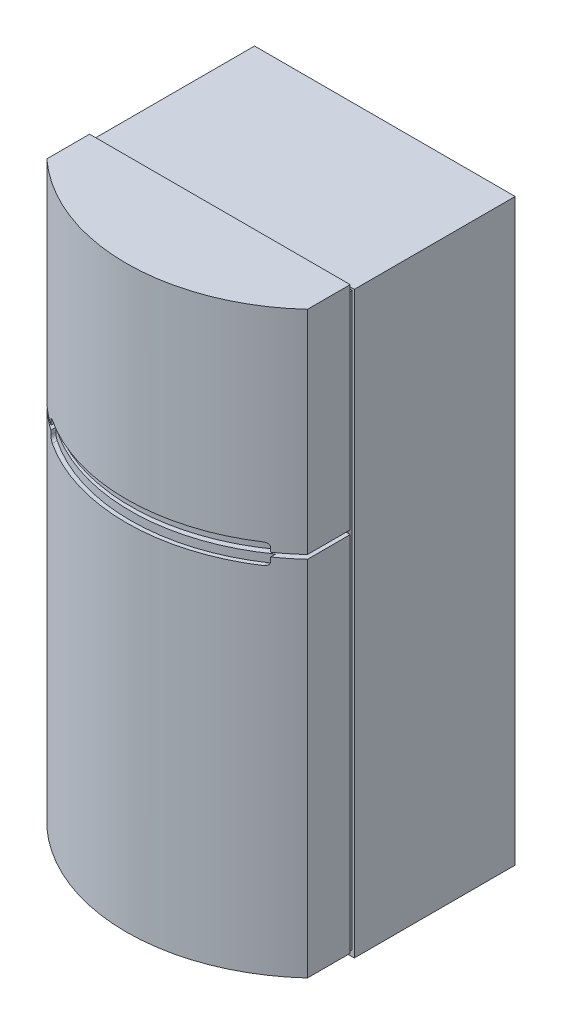
from build123d import *

# Parameters (mm, degrees)
SKETCH1_W               = 810
SKETCH1_H               = 500
BOSS_EXTRUDE1_DEPTH     = 1800
BOSS_EXTRUDE2_START     = 19.05
BOSS_EXTRUDE2_DEPTH     = 1800
SKETCH3_W               = 810
SKETCH3_H               = 12.7
CUT_EXTRUDE1_DEPTH      = 1712.976
CUT_EXTRUDE2_REACH      = 2031.39
CUT_EXTRUDE2_END_RADIUS = 585.872014924
SKETCH5_W               = 797.3
SKETCH5_H               = 1774.6
SKETCH5_W_2             = 771.9
SKETCH5_H_2             = 1749.2
EXTRUDE_THIN1_DEPTH     = 12.7
CUT_EXTRUDE3_DEPTH      = 1930.499391797


with BuildPart() as part:
    # Sketch1 → Boss-Extrude1 (new body)
    with BuildSketch(Plane(origin=(0, 0, 0), x_dir=(1, 0, 0), z_dir=(0, 1, 0))):
        Rectangle(SKETCH1_W, SKETCH1_H)
    extrude(amount=BOSS_EXTRUDE1_DEPTH)

    # Sketch6 → Cut-Extrude3 (cut, through all)
    with BuildSketch(Plane.XY.offset(250)):
        Polygon((-302.626047731, 0), (-268.027399007, 13.483618078), (268.027399007, 13.483618078), (302.626047731, 0), align=None)
    extrude(amount=-CUT_EXTRUDE3_DEPTH, mode=Mode.SUBTRACT)


with BuildPart() as body_2:
    # Sketch2 → Boss-Extrude2 (new body)
    with BuildSketch(Plane(origin=(0, 0, 0), x_dir=(1, 0, 0), z_dir=(0, 1, 0)).offset(BOSS_EXTRUDE2_START)):
        with BuildLine():
            Line((-405, -262.7), (405, -262.7))
            Line((405, -262.7), (405, -395.583268728))
            ThreePointArc((405, -395.583268728), (0, -553.402), (-405, -395.583268728))
            Line((-405, -395.583268728), (-405, -262.7))
        make_face()
    extrude(amount=BOSS_EXTRUDE2_DEPTH)

    # Sketch3 → Cut-Extrude1 (cut)
    with BuildSketch(Plane.XY.offset(553.402)):
        with Locations((0, 1152.493299562)):
            Rectangle(SKETCH3_W, SKETCH3_H)
    extrude(amount=-CUT_EXTRUDE1_DEPTH, mode=Mode.SUBTRACT)


with BuildPart() as cut_extrude1_piece_1:
    # of the separate pieces the step leaves, piece 1, a body of its own (cut_extrude1_pieces)
    add(body_2.part.solids().sort_by_distance((-405, 19.05, 395.583268728))[0])


with BuildPart() as cut_extrude1_piece_2:
    # of the separate pieces the step leaves, piece 2, a body of its own (cut_extrude1_pieces)
    add(body_2.part.solids().sort_by_distance((-405, 1158.843299562, 395.583268728))[0])


with BuildPart() as cut_extrude2_tool:
    # Cut-Extrude2: up to this cylinder (the profile starts outside it)
    cut_extrude2_end = Plane(origin=(0, 1152.4933, -45.170014924), z_dir=(0, -1, 0)) * Cylinder(CUT_EXTRUDE2_END_RADIUS, 5235.524029848, mode=Mode.PRIVATE)
    # Sketch4 → Cut-Extrude2 (new, up to the surface)
    with BuildSketch(Plane.XY.offset(553.402), mode=Mode.PRIVATE) as cut_extrude2_sk1:
        with BuildLine():
            Line((-328.8, 1184.243299562), (328.8, 1184.243299562))
            ThreePointArc((328.8, 1184.243299562), (337.780256121, 1180.523555683), (341.5, 1171.543299562))
            Line((341.5, 1171.543299562), (341.5, 1133.443299562))
            ThreePointArc((341.5, 1133.443299562), (337.780256121, 1124.463043441), (328.8, 1120.743299562))
            Line((328.8, 1120.743299562), (-328.8, 1120.743299562))
            ThreePointArc((-328.8, 1120.743299562), (-337.780256121, 1124.463043441), (-341.5, 1133.443299562))
            Line((-341.5, 1133.443299562), (-341.5, 1171.543299562))
            ThreePointArc((-341.5, 1171.543299562), (-337.780256121, 1180.523555683), (-328.8, 1184.243299562))
        make_face()
    cut_extrude2_tool1 = extrude(cut_extrude2_sk1.sketch, amount=-CUT_EXTRUDE2_REACH, mode=Mode.PRIVATE) - cut_extrude2_end
    add(cut_extrude2_tool1.solids().sort_by_distance((0, 1152.4933, 553.402))[0])


with BuildPart() as cut_extrude1_piece_1_1:
    add(cut_extrude1_piece_1.part)

    # Cut-Extrude2: cut by cut_extrude2_tool
    add(cut_extrude2_tool.part, mode=Mode.SUBTRACT)


with BuildPart() as cut_extrude1_piece_2_1:
    add(cut_extrude1_piece_2.part)

    # Cut-Extrude2: cut by cut_extrude2_tool
    add(cut_extrude2_tool.part, mode=Mode.SUBTRACT)


with BuildPart() as body_4:
    # Sketch5 → Extrude-Thin1 (new body)
    with BuildSketch(Plane.XY.offset(250)):
        with Locations((0, 906.35)):
            Rectangle(SKETCH5_W, SKETCH5_H)
        with Locations((0, 906.35)):
            Rectangle(SKETCH5_W_2, SKETCH5_H_2, mode=Mode.SUBTRACT)
    extrude(amount=EXTRUDE_THIN1_DEPTH)


solid = Compound([part.part, cut_extrude1_piece_1_1.part, cut_extrude1_piece_2_1.part, body_4.part])
